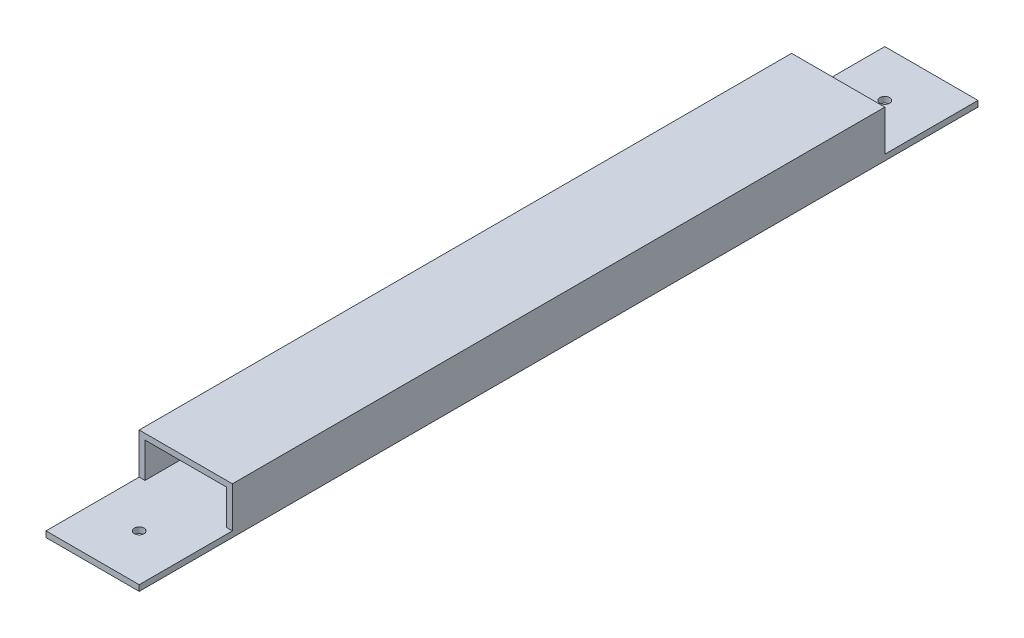
from build123d import *

# Parameters (mm, degrees)
SKETCH1_W           = 50.8
SKETCH1_H           = 25.4
SKETCH1_W_2         = 44.45
SKETCH1_H_2         = 19.05
BOSS_EXTRUDE1_DEPTH = 457.2
SKETCH2_R           = 2.667
CUT_EXTRUDE1_DEPTH  = 26.4
SKETCH3_W           = 50.8
SKETCH3_H           = 50.8
CUT_EXTRUDE2_DEPTH  = 22.225


with BuildPart() as part:
    # Sketch1 → Boss-Extrude1 (new body)
    with BuildSketch(Plane.XY):
        Rectangle(SKETCH1_W, SKETCH1_H)
        Rectangle(SKETCH1_W_2, SKETCH1_H_2, mode=Mode.SUBTRACT)
    extrude(amount=BOSS_EXTRUDE1_DEPTH)

    # Sketch2 → Cut-Extrude1 (cut, through all)
    with BuildSketch(Plane(origin=(0, 12.7, 0), x_dir=(1, 0, 0), z_dir=(0, 1, 0))):
        with Locations((0, -431.8)):
            Circle(SKETCH2_R)
        with Locations((0, -25.4)):
            Circle(SKETCH2_R)
    extrude(amount=-CUT_EXTRUDE1_DEPTH, mode=Mode.SUBTRACT)

    # Sketch3 → Cut-Extrude2 (cut)
    with BuildSketch(Plane(origin=(0, 12.7, 0), x_dir=(1, 0, 0), z_dir=(0, 1, 0))):
        with Locations((0, -431.8)):
            Rectangle(SKETCH3_W, SKETCH3_H)
        with Locations((0, -25.4)):
            Rectangle(SKETCH3_W, SKETCH3_H)
    extrude(amount=-CUT_EXTRUDE2_DEPTH, mode=Mode.SUBTRACT)


solid = part.part
